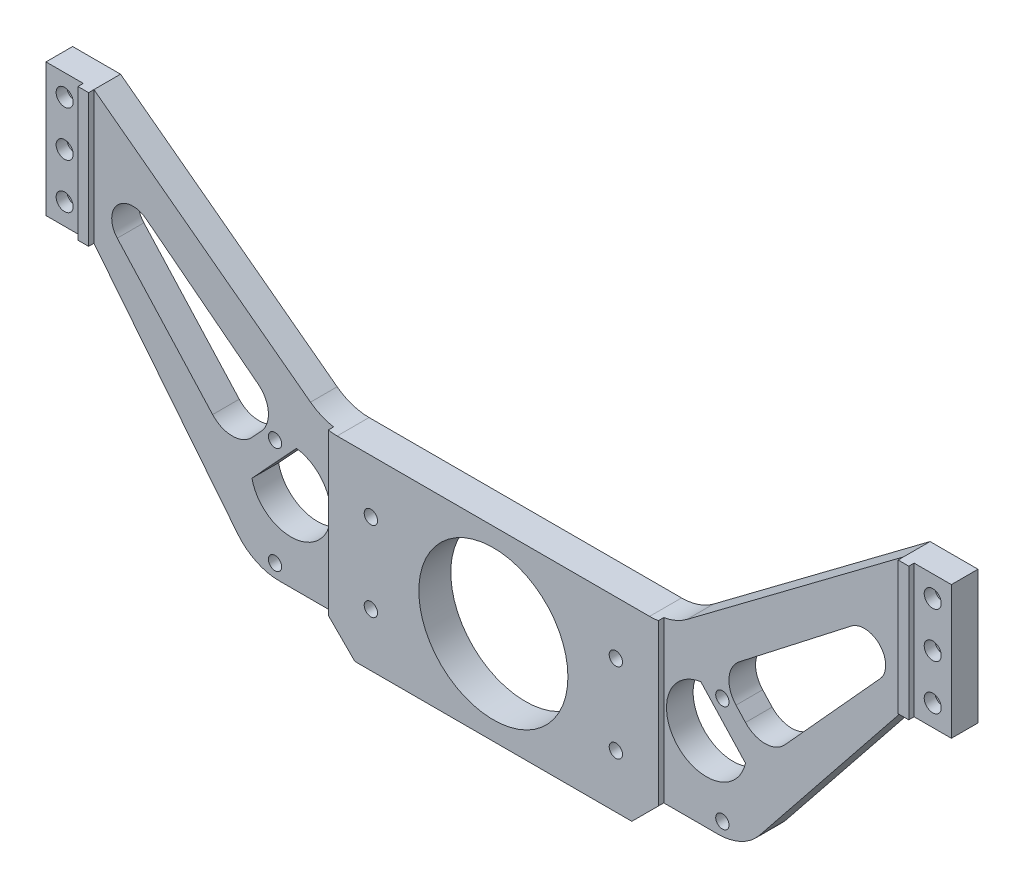
from build123d import *

# Parameters (mm, degrees)
SKETCH_1_R             = 14
EXTRUDE_1_DEPTH        = 5
SKETCH_2_W             = 2
SKETCH_2_H             = 25
EXTRUDE_2_DEPTH        = 1
CUT_EXTRUDE_2_REACH    = 7
HOLE_WIZARD_M3_1_D     = 2.5
HOLE_WIZARD_M3_1_DEPTH = 8.5
HOLE_WIZARD_M3_1_TIP   = 0.751075774
SKETCH_9_R             = 14
EXTRUDE_3_DEPTH        = 1
HOLE_WIZARD_M3_3_D     = 2.5
HOLE_WIZARD_M3_3_DEPTH = 8.5
HOLE_WIZARD_M3_3_TIP   = 0.751075774
CUT_EXTRUDE_3_REACH    = 7
SKETCH_12_R            = 1.6
SKETCH_13_R            = 3
CUT_EXTRUDE_4_DEPTH    = 3


with BuildPart() as part:
    # 草图1 → 凸台-拉伸1 (new body)
    with BuildSketch(Plane.XY):
        with BuildLine():
            Line((-85, 25), (-85, 50))
            Line((-85, 50), (-76, 50))
            Line((-76, 50), (-35.333333333, 19.5))
            ThreePointArc((-35.333333333, 19.5), (-32.495610994, 18.013167019), (-29.333333333, 17.5))
            Line((-29.333333333, 17.5), (29.333333333, 17.5))
            ThreePointArc((29.333333333, 17.5), (32.495610994, 18.013167019), (35.333333333, 19.5))
            Line((35.333333333, 19.5), (76, 50))
            Line((76, 50), (85, 50))
            Line((85, 50), (85, 25))
            Line((85, 25), (76, 25))
            Line((76, 25), (49.00243962, -8.746950476))
            ThreePointArc((49.00243962, -8.746950476), (45.52563883, -11.513032363), (41.193751525, -12.5))
            Line((41.193751525, -12.5), (31, -12.5))
            Line((31, -12.5), (26, -17.5))
            Line((26, -17.5), (-26, -17.5))
            Line((-26, -17.5), (-31, -12.5))
            Line((-31, -12.5), (-41.193751525, -12.5))
            ThreePointArc((-41.193751525, -12.5), (-45.52563883, -11.513032363), (-49.00243962, -8.746950476))
            Line((-49.00243962, -8.746950476), (-76, 25))
            Line((-76, 25), (-85, 25))
        make_face()
        Circle(SKETCH_1_R, mode=Mode.SUBTRACT)
    extrude(amount=EXTRUDE_1_DEPTH)

    # 草图2 → 凸台-拉伸2 (add)
    with BuildSketch(Plane.XY.offset(5)):
        with Locations((-77, 37.5)):
            Rectangle(SKETCH_2_W, SKETCH_2_H)
        with Locations((77, 37.5)):
            Rectangle(SKETCH_2_W, SKETCH_2_H)
    extrude(amount=EXTRUDE_2_DEPTH)

    # 草图3 → 切除-拉伸2 (cut, up to next)
    with BuildSketch(Plane.XY.offset(5), mode=Mode.PRIVATE) as cut_extrude_2_sk1:
        with BuildLine():
            Line((-71.624088, 28.017247632), (-53.714483662, 8.288938763))
            ThreePointArc((-53.714483662, 8.288938763), (-50.037049276, 6.649771189), (-46.343650352, 8.252643109))
            Line((-46.343650352, 8.252643109), (-44.561564605, 10.177266985))
            ThreePointArc((-44.561564605, 10.177266985), (-43.247059214, 13.982850984), (-45.163793368, 17.523546422))
            Line((-45.163793368, 17.523546422), (-66.209204362, 33.865234658))
            ThreePointArc((-66.209204362, 33.865234658), (-71.597466294, 33.423519047), (-71.624088, 28.017247632))
        make_face()
    cut_extrude_2_tool1 = extrude(cut_extrude_2_sk1.sketch, amount=-CUT_EXTRUDE_2_REACH, mode=Mode.PRIVATE) & part.part
    add(cut_extrude_2_tool1.solids().sort_by_distance((-57.416432, 20.292736, 5))[0], mode=Mode.SUBTRACT)
    # 草图3 → 切除-拉伸2 (cut, up to next)
    with BuildSketch(Plane.XY.offset(5), mode=Mode.PRIVATE) as cut_extrude_2_sk2:
        with BuildLine():
            Line((44.878567193, 3.211549518), (46.335374238, 1.638221397))
            ThreePointArc((46.335374238, 1.638221397), (45.673933781, -0.192361307), (44.563707744, -1.791090382))
            ThreePointArc((44.563707744, -1.791090382), (33.507457779, -1.845533864), (34.410800923, 9.173885293))
            ThreePointArc((34.410800923, 9.173885293), (36.090068224, 10.158058978), (37.966040159, 10.676967267))
            Line((37.966040159, 10.676967267), (44.878567193, 3.211549518))
        make_face()
    cut_extrude_2_tool2 = extrude(cut_extrude_2_sk2.sketch, amount=-CUT_EXTRUDE_2_REACH, mode=Mode.PRIVATE) & part.part
    add(cut_extrude_2_tool2.solids().sort_by_distance((38.242863, 2.539166, 5))[0], mode=Mode.SUBTRACT)
    # 草图3 → 切除-拉伸2 (cut, up to next)
    with BuildSketch(Plane.XY.offset(5), mode=Mode.PRIVATE) as cut_extrude_2_sk3:
        with BuildLine():
            Line((-44.878567193, 3.211549518), (-46.335374238, 1.638221397))
            ThreePointArc((-46.335374238, 1.638221397), (-45.673933781, -0.192361307), (-44.563707744, -1.791090382))
            ThreePointArc((-44.563707744, -1.791090382), (-33.507457779, -1.845533864), (-34.410800923, 9.173885293))
            ThreePointArc((-34.410800923, 9.173885293), (-36.090068224, 10.158058978), (-37.966040159, 10.676967267))
            Line((-37.966040159, 10.676967267), (-44.878567193, 3.211549518))
        make_face()
    cut_extrude_2_tool3 = extrude(cut_extrude_2_sk3.sketch, amount=-CUT_EXTRUDE_2_REACH, mode=Mode.PRIVATE) & part.part
    add(cut_extrude_2_tool3.solids().sort_by_distance((-38.242863, 2.539166, 5))[0], mode=Mode.SUBTRACT)
    # 草图3 → 切除-拉伸2 (cut, up to next)
    with BuildSketch(Plane.XY.offset(5), mode=Mode.PRIVATE) as cut_extrude_2_sk4:
        with BuildLine():
            Line((46.343650352, 8.252643109), (44.561564605, 10.177266985))
            ThreePointArc((44.561564605, 10.177266985), (43.247059214, 13.982850984), (45.163793368, 17.523546422))
            Line((45.163793368, 17.523546422), (66.209204362, 33.865234658))
            ThreePointArc((66.209204362, 33.865234658), (71.597466294, 33.423519047), (71.624088, 28.017247632))
            Line((71.624088, 28.017247632), (53.714483662, 8.288938763))
            ThreePointArc((53.714483662, 8.288938763), (50.037049276, 6.649771189), (46.343650352, 8.252643109))
        make_face()
    cut_extrude_2_tool4 = extrude(cut_extrude_2_sk4.sketch, amount=-CUT_EXTRUDE_2_REACH, mode=Mode.PRIVATE) & part.part
    add(cut_extrude_2_tool4.solids().sort_by_distance((57.416432, 20.292736, 5))[0], mode=Mode.SUBTRACT)

    # M3 螺纹孔1
    with Locations(Plane(origin=(-42, 10, 5), x_dir=(1, 0, 0), z_dir=(0, 0, 1))):
        with Locations((0, 0), (0, -20), (84, 0), (84, -20)):
            Hole(HOLE_WIZARD_M3_1_D / 2, depth=HOLE_WIZARD_M3_1_DEPTH)
            with Locations((0, 0, -(HOLE_WIZARD_M3_1_DEPTH + HOLE_WIZARD_M3_1_TIP / 2))):  # 118° drill point
                Cone(0, HOLE_WIZARD_M3_1_D / 2, HOLE_WIZARD_M3_1_TIP, mode=Mode.SUBTRACT)

    # 草图9 → 凸台-拉伸3 (add)
    with BuildSketch(Plane.XY.offset(5)):
        with BuildLine():
            Line((-31, -12.5), (-31, 17.639867028))
            ThreePointArc((-31, 17.639867028), (-30.169595936, 17.535028105), (-29.333333333, 17.5))
            Line((-29.333333333, 17.5), (29.333333333, 17.5))
            ThreePointArc((29.333333333, 17.5), (30.169595936, 17.535028105), (31, 17.639867028))
            Line((31, 17.639867028), (31, -12.5))
            Line((31, -12.5), (26, -17.5))
            Line((26, -17.5), (-26, -17.5))
            Line((-26, -17.5), (-31, -12.5))
        make_face()
        Circle(SKETCH_9_R, mode=Mode.SUBTRACT)
    extrude(amount=EXTRUDE_3_DEPTH)

    # M3 螺纹孔3
    with Locations(Plane(origin=(-23, 7.5, 6), x_dir=(1, 0, 0), z_dir=(0, 0, 1))):
        with Locations((0, 0), (0, -15), (46, -15), (46, 0)):
            Hole(HOLE_WIZARD_M3_3_D / 2, depth=HOLE_WIZARD_M3_3_DEPTH)
            with Locations((0, 0, -(HOLE_WIZARD_M3_3_DEPTH + HOLE_WIZARD_M3_3_TIP / 2))):  # 118° drill point
                Cone(0, HOLE_WIZARD_M3_3_D / 2, HOLE_WIZARD_M3_3_TIP, mode=Mode.SUBTRACT)

    # 草图12 → 切除-拉伸3 (cut, up to next)
    with BuildSketch(Plane.XY.offset(5), mode=Mode.PRIVATE) as cut_extrude_3_sk1:
        with Locations((-81.5, 37.5)):
            Circle(SKETCH_12_R)
    cut_extrude_3_tool1 = extrude(cut_extrude_3_sk1.sketch, amount=-CUT_EXTRUDE_3_REACH, mode=Mode.PRIVATE) & part.part
    add(cut_extrude_3_tool1.solids().sort_by_distance((-81.5, 37.5, 5))[0], mode=Mode.SUBTRACT)
    # 草图12 → 切除-拉伸3 (cut, up to next)
    with BuildSketch(Plane.XY.offset(5), mode=Mode.PRIVATE) as cut_extrude_3_sk2:
        with Locations((-81.5, 29)):
            Circle(SKETCH_12_R)
    cut_extrude_3_tool2 = extrude(cut_extrude_3_sk2.sketch, amount=-CUT_EXTRUDE_3_REACH, mode=Mode.PRIVATE) & part.part
    add(cut_extrude_3_tool2.solids().sort_by_distance((-81.5, 29, 5))[0], mode=Mode.SUBTRACT)
    # 草图12 → 切除-拉伸3 (cut, up to next)
    with BuildSketch(Plane.XY.offset(5), mode=Mode.PRIVATE) as cut_extrude_3_sk3:
        with Locations((-81.5, 46)):
            Circle(SKETCH_12_R)
    cut_extrude_3_tool3 = extrude(cut_extrude_3_sk3.sketch, amount=-CUT_EXTRUDE_3_REACH, mode=Mode.PRIVATE) & part.part
    add(cut_extrude_3_tool3.solids().sort_by_distance((-81.5, 46, 5))[0], mode=Mode.SUBTRACT)
    # 草图12 → 切除-拉伸3 (cut, up to next)
    with BuildSketch(Plane.XY.offset(5), mode=Mode.PRIVATE) as cut_extrude_3_sk4:
        with Locations((81.5, 46)):
            Circle(SKETCH_12_R)
    cut_extrude_3_tool4 = extrude(cut_extrude_3_sk4.sketch, amount=-CUT_EXTRUDE_3_REACH, mode=Mode.PRIVATE) & part.part
    add(cut_extrude_3_tool4.solids().sort_by_distance((81.5, 46, 5))[0], mode=Mode.SUBTRACT)
    # 草图12 → 切除-拉伸3 (cut, up to next)
    with BuildSketch(Plane.XY.offset(5), mode=Mode.PRIVATE) as cut_extrude_3_sk5:
        with Locations((81.5, 29)):
            Circle(SKETCH_12_R)
    cut_extrude_3_tool5 = extrude(cut_extrude_3_sk5.sketch, amount=-CUT_EXTRUDE_3_REACH, mode=Mode.PRIVATE) & part.part
    add(cut_extrude_3_tool5.solids().sort_by_distance((81.5, 29, 5))[0], mode=Mode.SUBTRACT)
    # 草图12 → 切除-拉伸3 (cut, up to next)
    with BuildSketch(Plane.XY.offset(5), mode=Mode.PRIVATE) as cut_extrude_3_sk6:
        with Locations((81.5, 37.5)):
            Circle(SKETCH_12_R)
    cut_extrude_3_tool6 = extrude(cut_extrude_3_sk6.sketch, amount=-CUT_EXTRUDE_3_REACH, mode=Mode.PRIVATE) & part.part
    add(cut_extrude_3_tool6.solids().sort_by_distance((81.5, 37.5, 5))[0], mode=Mode.SUBTRACT)

    # 草图13 → 切除-拉伸4 (cut)
    with BuildSketch(Plane(origin=(0, 0, 0), x_dir=(-1, 0, 0), z_dir=(0, 0, -1))):
        with Locations((-81.5, 37.5)):
            Circle(SKETCH_13_R)
        with Locations((-81.5, 46)):
            Circle(SKETCH_13_R)
        with Locations((-81.5, 29)):
            Circle(SKETCH_13_R)
        with Locations((81.5, 29)):
            Circle(SKETCH_13_R)
        with Locations((81.5, 37.5)):
            Circle(SKETCH_13_R)
        with Locations((81.5, 46)):
            Circle(SKETCH_13_R)
    extrude(amount=-CUT_EXTRUDE_4_DEPTH, mode=Mode.SUBTRACT)


solid = part.part
